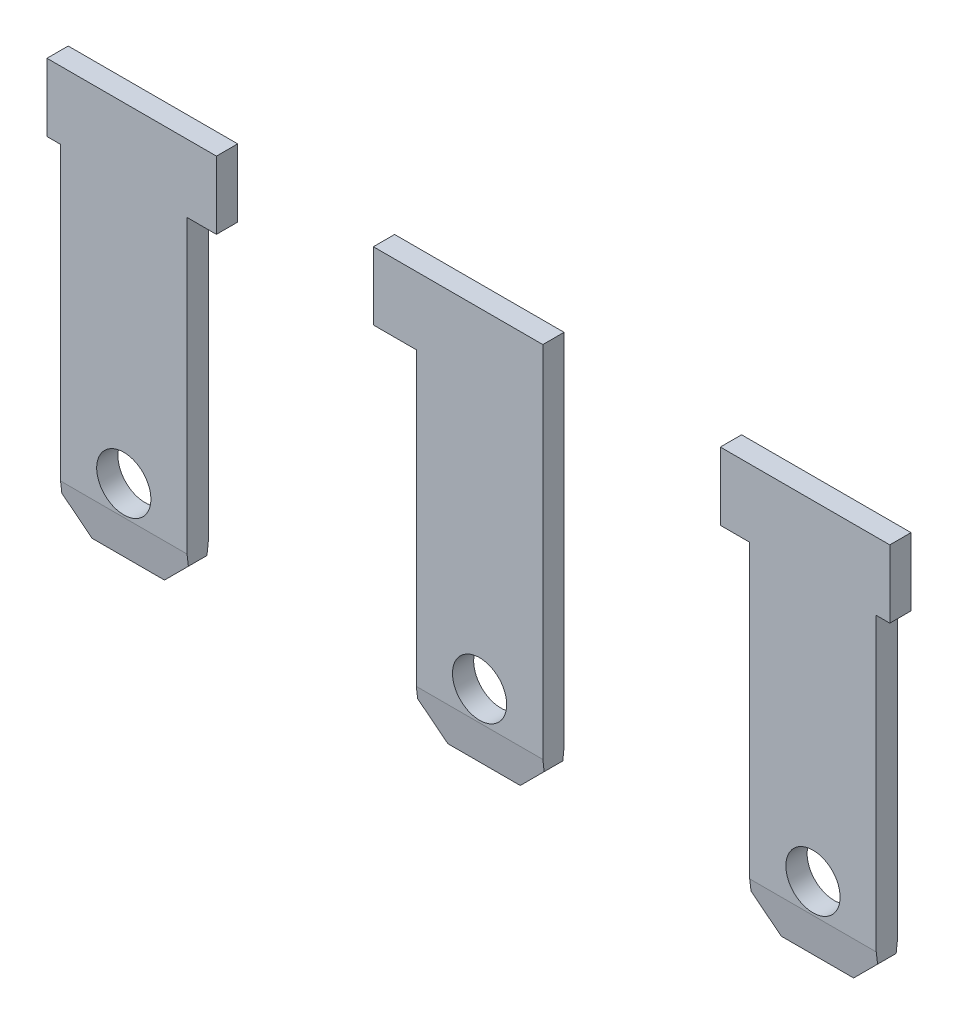
from build123d import *

# Parameters (mm, degrees)
SKETCH1_R               = 0.6
BOSS_EXTRUDE1_DEPTH     = 0.47
BOSS_EXTRUDE1_2_DEPTH   = 0.47
BOSS_EXTRUDE1_3_DEPTH   = 0.47
CUT_EXTRUDE1_DEPTH      = 12.192857143
CUT_EXTRUDE1_DEPTH_BACK = 8.457142857


with BuildPart() as part:
    # Sketch1 → Boss-Extrude1 (new body)
    with BuildSketch(Plane.XY):
        Polygon((-7.457142857, -3.580592992), (-3.707142857, -3.580592992), (-3.707142857, -5.080592992), (-4.357142857, -5.080592992), (-4.357142857, -11.780592992), (-4.957142857, -12.380592992), (-6.557142857, -12.380592992), (-7.157142857, -11.780592992), (-7.157142857, -5.080592992), (-7.457142857, -5.080592992), align=None)
        with Locations((-5.757142857, -10.880592992)):
            Circle(SKETCH1_R, mode=Mode.SUBTRACT)
    extrude(amount=BOSS_EXTRUDE1_DEPTH)


with BuildPart() as body_2:
    # Sketch1 → Boss-Extrude1 2 (new body)
    with BuildSketch(Plane.XY):
        Polygon((-0.234501348, -3.580592992), (3.515498652, -3.580592992), (3.515498652, -5.080592992), (3.515498652, -11.780592992), (2.915498652, -12.380592992), (1.315498652, -12.380592992), (0.715498652, -11.780592992), (0.715498652, -5.080592992), (-0.234501348, -5.080592992), align=None)
        with Locations((2.115498652, -10.880592992)):
            Circle(SKETCH1_R, mode=Mode.SUBTRACT)
    extrude(amount=BOSS_EXTRUDE1_2_DEPTH)


with BuildPart() as body_3:
    # Sketch1 → Boss-Extrude1 3 (new body)
    with BuildSketch(Plane.XY):
        Polygon((11.192857143, -3.580592992), (7.442857143, -3.580592992), (7.442857143, -5.080592992), (8.092857143, -5.080592992), (8.092857143, -11.780592992), (8.692857143, -12.380592992), (10.292857143, -12.380592992), (10.892857143, -11.780592992), (10.892857143, -5.080592992), (11.192857143, -5.080592992), align=None)
        with Locations((9.492857143, -10.880592992)):
            Circle(SKETCH1_R, mode=Mode.SUBTRACT)
    extrude(amount=BOSS_EXTRUDE1_3_DEPTH)


with BuildPart() as cut_extrude1_tool:
    # Sketch2 → Cut-Extrude1 (new body, two sides)
    with BuildSketch(Plane(origin=(0, 0, 0), x_dir=(0, 0, -1), z_dir=(1, 0, 0))) as cut_extrude1_sk:
        Polygon((-0.47, -11.530592992), (-0.37, -12.380592992), (-0.47, -12.380592992), align=None)
        Polygon((-0.1, -12.380592992), (0, -12.380592992), (0, -11.530592992), align=None)
    extrude(amount=CUT_EXTRUDE1_DEPTH)
    extrude(cut_extrude1_sk.sketch, amount=-CUT_EXTRUDE1_DEPTH_BACK)


with BuildPart() as part_1:
    add(part.part)

    # Cut-Extrude1: cut by cut_extrude1_tool
    add(cut_extrude1_tool.part, mode=Mode.SUBTRACT)


with BuildPart() as body_2_1:
    add(body_2.part)

    # Cut-Extrude1: cut by cut_extrude1_tool
    add(cut_extrude1_tool.part, mode=Mode.SUBTRACT)


with BuildPart() as body_3_1:
    add(body_3.part)

    # Cut-Extrude1: cut by cut_extrude1_tool
    add(cut_extrude1_tool.part, mode=Mode.SUBTRACT)


solid = Compound([part_1.part, body_2_1.part, body_3_1.part])
